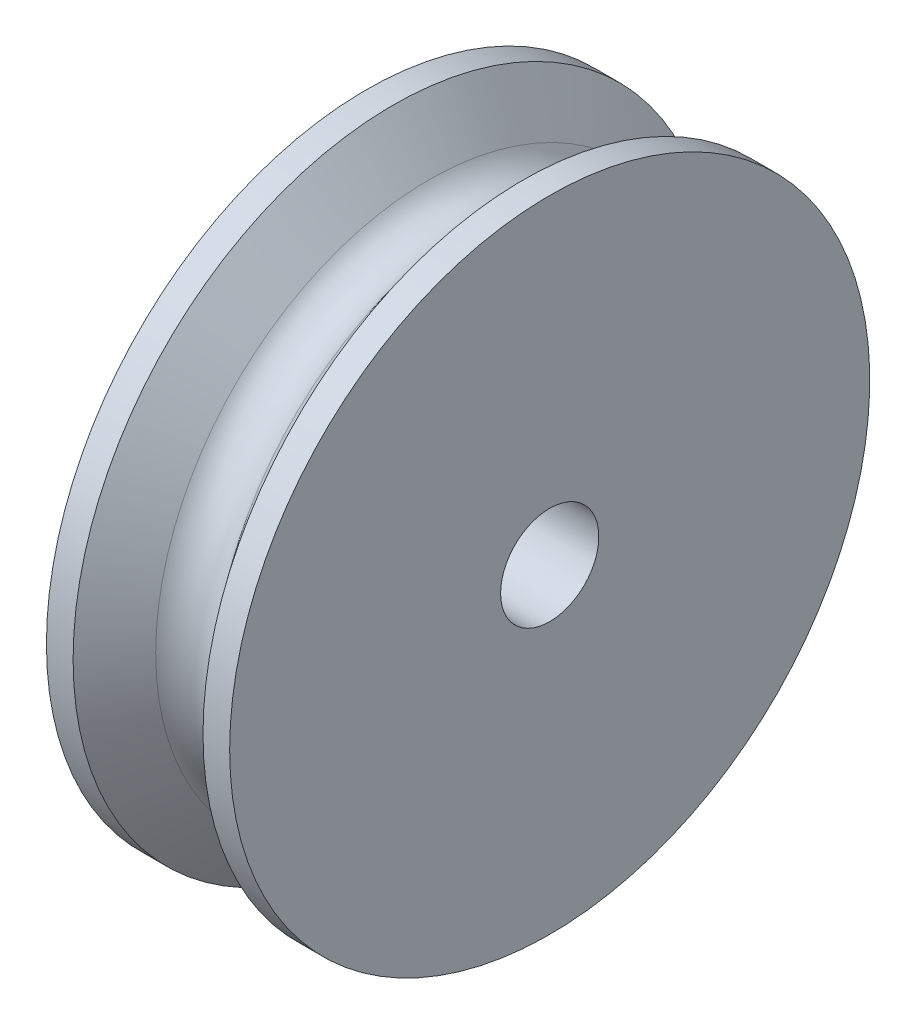
from build123d import *


with BuildPart() as part:
    # Sketch1 → Revolve1 (revolve)
    with BuildSketch(Plane.XY):
        with BuildLine():
            Line((0, 2.5527), (9.525, 2.5527))
            Line((9.525, 2.5527), (9.525, 16.637))
            Line((9.525, 16.637), (8.138205223, 16.637))
            Line((8.138205223, 16.637), (6.273838113, 14.207309478))
            ThreePointArc((6.273838113, 14.207309478), (4.7625, 13.462), (3.251161887, 14.207309478))
            Line((3.251161887, 14.207309478), (1.386794777, 16.637))
            Line((1.386794777, 16.637), (0, 16.637))
            Line((0, 16.637), (0, 2.5527))
        make_face()
    revolve(axis=Axis((0, 0, 0), (1, 0, 0)))


solid = part.part
